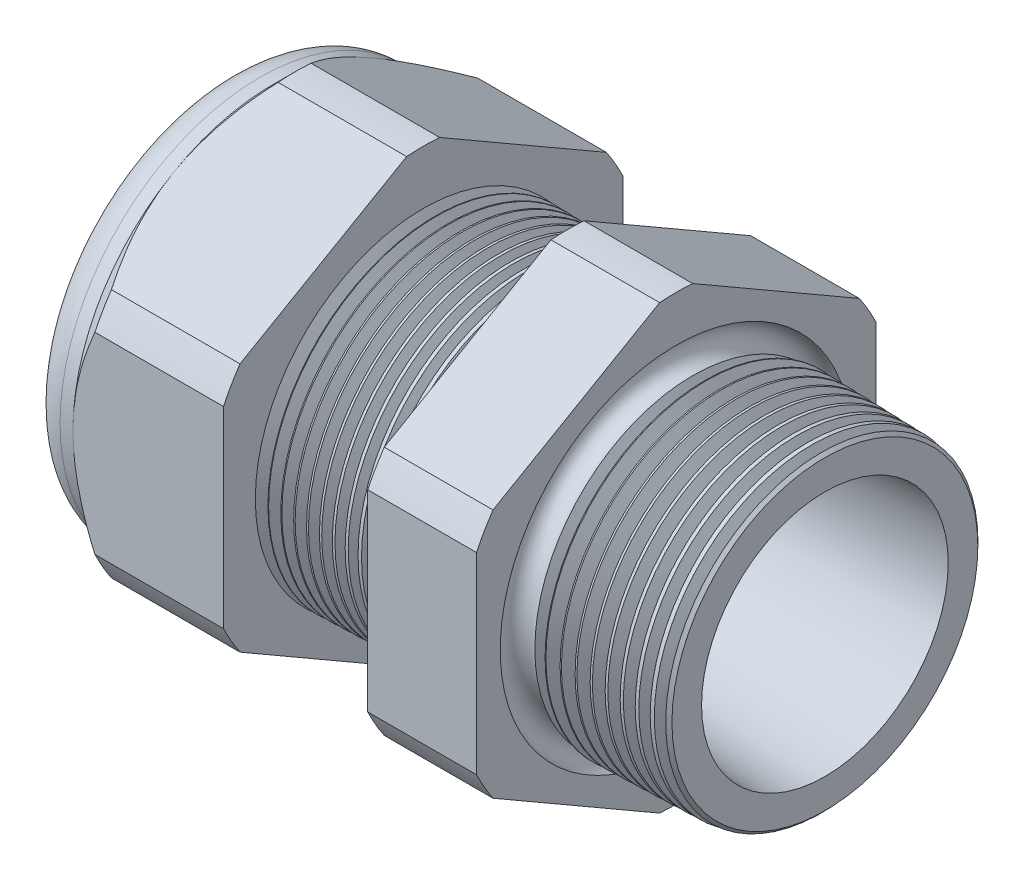
from build123d import *

# Parameters (mm, degrees)
SKETCH12_OUTSIDE_W = 65.04
SKETCH12_OUTSIDE_H = 65.04
CUT_EXTRUDE2_DEPTH = 34.014
FILLET4_R          = 2.032
SKETCH19_OUTSIDE_W = 39.986
SKETCH19_OUTSIDE_H = 42.612
SKETCH19_OUTSIDE_R = 11.938
CUT_EXTRUDE3_DEPTH = 1.999996
CUT_EXTRUDE3_DRAFT = -45
CHAMFER1_SIZE      = 0.260919487
CHAMFER1_SIZE2     = 0.254
SKETCH21_R         = 5.969
PLUG_DEPTH         = 6.35
SKETCH22_R         = 5.715
CUT_EXTRUDE4_DEPTH = 0.508
SKETCH27_R         = 1.27
PLUGHOLES_DEPTH    = 36.306
CIRPATTERN1_COUNT  = 2
LPATTERN1_COUNT    = 11
LPATTERN1_PITCH    = 0.762
LPATTERN2_COUNT    = 10
LPATTERN2_PITCH    = 0.889
SKETCH32_R         = 0.889


with BuildPart() as part:
    # Sketch10 → Revolve2 (revolve)
    with BuildSketch(Plane.XY, mode=Mode.PRIVATE) as revolve2_sk:
        Polygon((-34.798, 5.969), (-22.998, 5.969), (1.016, 7.372171279), (1.016, 9.404171279), (-7.874, 9.636964122), (-7.874, 23.876), (-14.374, 23.876), (-14.374, 9.807172612), (-22.998, 10.033), (-22.998, 23.876), (-31.998, 23.876), (-31.998, 11.938), (-34.798, 11.938), align=None)
    revolve(revolve2_sk.sketch.rotate(Axis((0, 0, 0), (-1, 0, 0)), 90), axis=Axis((0, 0, 0), (-1, 0, 0)))  # turned: the seam where the file's is

    # Sketch12 outside → Cut-Extrude2 (cut, through all)
    with BuildSketch(Plane.ZY.offset(31.998)):
        Rectangle(SKETCH12_OUTSIDE_W, SKETCH12_OUTSIDE_H)
        with BuildLine():
            Line((-0.98819228, 13.214281948), (-10.94980772, 7.462940592))
            ThreePointArc((-10.94980772, 7.462940592), (-11.47585851, 6.62559), (-11.938, 5.751341356))
            Line((-11.938, 5.751341356), (-11.938, -5.751341356))
            ThreePointArc((-11.938, -5.751341356), (-11.47585851, -6.62559), (-10.94980772, -7.462940592))
            Line((-10.94980772, -7.462940592), (-0.98819228, -13.214281948))
            ThreePointArc((-0.98819228, -13.214281948), (0, -13.25118), (0.98819228, -13.214281948))
            Line((0.98819228, -13.214281948), (10.94980772, -7.462940592))
            ThreePointArc((10.94980772, -7.462940592), (11.47585851, -6.62559), (11.938, -5.751341356))
            Line((11.938, -5.751341356), (11.938, 5.751341356))
            ThreePointArc((11.938, 5.751341356), (11.47585851, 6.62559), (10.94980772, 7.462940592))
            Line((10.94980772, 7.462940592), (0.98819228, 13.214281948))
            ThreePointArc((0.98819228, 13.214281948), (0, 13.25118), (-0.98819228, 13.214281948))
        make_face(mode=Mode.SUBTRACT)
    extrude(amount=-CUT_EXTRUDE2_DEPTH, mode=Mode.SUBTRACT)

    # Fillet4
    fillet4_edges = [part.edges().sort_by_distance(p)[0] for p in [
        (-34.798, 0, 11.938),
    ]]
    fillet(fillet4_edges, radius=FILLET4_R)


with BuildPart() as cut_extrude3_tool:
    # Sketch19 outside → Cut-Extrude3 (with draft: the straight prism first)
    with BuildSketch(Plane.ZY.offset(31.998)):
        Rectangle(SKETCH19_OUTSIDE_W, SKETCH19_OUTSIDE_H)
        Circle(SKETCH19_OUTSIDE_R, mode=Mode.SUBTRACT)
    extrude(amount=-CUT_EXTRUDE3_DEPTH)
    # Cut-Extrude3: the draft: its side faces are tilted about the plane it starts from
    cut_extrude3_sides = [cut_extrude3_tool.faces().sort_by_distance(p)[0] for p in [
        (-30.998002, -21.306, 0),
        (-30.998002, 0, 19.993),
        (-30.998002, 21.306, 0),
        (-30.998002, 0, -19.993),
        (-30.998002, 0, -11.938),
    ]]
    draft(cut_extrude3_sides, Plane.ZY.offset(31.998), CUT_EXTRUDE3_DRAFT)


with BuildPart() as part_1:
    add(part.part)

    # Cut-Extrude3: cut by cut_extrude3_tool
    add(cut_extrude3_tool.part, mode=Mode.SUBTRACT)

    # Chamfer1
    chamfer1_edges = [part_1.edges().sort_by_distance(p)[0] for p in [
        (1.016, 0, 9.404171279),
    ]]
    chamfer1_side = [part_1.faces().sort_by_distance(p)[0] for p in [
        (1.016, 0, 7.638161411),
    ]]
    chamfer(chamfer1_edges, length=CHAMFER1_SIZE, length2=CHAMFER1_SIZE2, reference=chamfer1_side[0])

    # Sketch29 → Cut-Revolve1 (revolve, cut)
    with BuildSketch(Plane.XY, mode=Mode.PRIVATE) as cut_revolve1_sk:
        Polygon((-22.998, 10.033), (-22.265016419, 10.013806149), (-22.648130572, 9.388620673), align=None)
    cut_revolve1 = revolve(cut_revolve1_sk.sketch.rotate(Axis((0, 0, 0), (-1, 0, 0)), 90), axis=Axis((0, 0, 0), (-1, 0, 0)), mode=Mode.SUBTRACT)  # turned: the seam where the file's is

    # LPattern1: Cut-Revolve1 ×11
    with Locations(*[(i * LPATTERN1_PITCH, 0, 0) for i in range(1, LPATTERN1_COUNT)]):
        add(cut_revolve1, mode=Mode.SUBTRACT)

    # Sketch30 → Cut-Revolve2 (revolve, cut)
    with BuildSketch(Plane.XY, mode=Mode.PRIVATE) as cut_revolve2_sk:
        Polygon((-7.874, 9.636964122), (-6.994419703, 9.613931502), (-7.454156686, 8.86370893), align=None)
    cut_revolve2 = revolve(cut_revolve2_sk.sketch.rotate(Axis((0, 0, 0), (-1, 0, 0)), 270), axis=Axis((0, 0, 0), (-1, 0, 0)), mode=Mode.SUBTRACT)  # turned: the seam where the file's is

    # LPattern2: Cut-Revolve2 ×10
    with Locations(*[(i * LPATTERN2_PITCH, 0, 0) for i in range(1, LPATTERN2_COUNT)]):
        add(cut_revolve2, mode=Mode.SUBTRACT)

    # Sketch32 → Cut-Revolve3 (revolve, cut)
    with BuildSketch(Plane.XY, mode=Mode.PRIVATE) as cut_revolve3_sk:
        with Locations((-7.747, 9.636964122)):
            Circle(SKETCH32_R)
    revolve(cut_revolve3_sk.sketch.rotate(Axis((0, 0, 0), (-1, 0, 0)), 270), axis=Axis((0, 0, 0), (-1, 0, 0)), mode=Mode.SUBTRACT)  # turned: the seam where the file's is


with BuildPart() as body_2:
    # Sketch21 → plug (new body)
    with BuildSketch(Plane.ZY.offset(34.798)):
        Circle(SKETCH21_R)
    extrude(amount=-PLUG_DEPTH)

    # Sketch22 → Cut-Extrude4 (cut)
    with BuildSketch(Plane.ZY.offset(34.798)):
        Circle(SKETCH22_R)
    extrude(amount=-CUT_EXTRUDE4_DEPTH, mode=Mode.SUBTRACT)

    # Sketch27 → plugholes (cut, through all)
    with BuildSketch(Plane.ZY.offset(34.29)):
        with Locations((-4.43992, 0)):
            Circle(SKETCH27_R)
    plugholes = extrude(amount=-PLUGHOLES_DEPTH, mode=Mode.SUBTRACT)

    # CirPattern1: plugholes ×2 about axis
    cirpattern1_axis = Axis((0, 0, 0), (1, 0, 0))
    for i in range(1, CIRPATTERN1_COUNT):
        add(plugholes.rotate(cirpattern1_axis, i * 360 / CIRPATTERN1_COUNT), mode=Mode.SUBTRACT)


solid = Compound([part_1.part, body_2.part])
